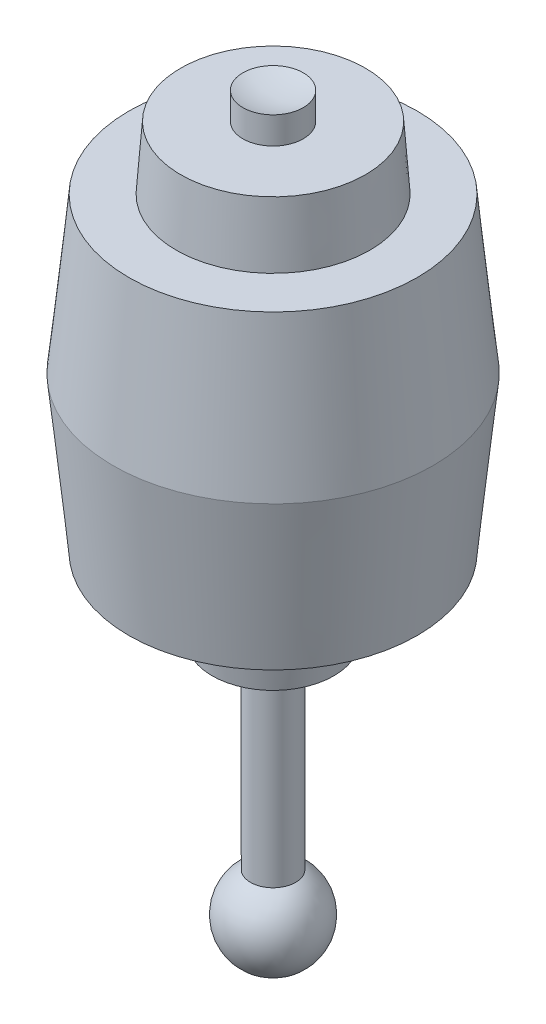
from build123d import *


with BuildPart() as part:
    # Sketch1 → Revolve1 (revolve)
    with BuildSketch(Plane.XY):
        with BuildLine():
            Line((-2.5, -47.669872981), (-2.5, -25.7))
            Line((-2.5, -25.7), (-6.75, -25.7))
            Line((-6.75, -25.7), (-7.75, -17.2))
            Line((-7.75, -17.2), (-16, -17.2))
            Line((-16, -17.2), (-17.75, 0))
            Line((-17.75, 0), (-16, 17.2))
            Line((-16, 17.2), (-10.75, 17.2))
            Line((-10.75, 17.2), (-10.25, 24.2))
            Line((-10.25, 24.2), (-3.35, 24.2))
            Line((-3.35, 24.2), (-3.35, 27.2))
            ThreePointArc((-3.35, 27.2), (-1.699733397, 26.767694664), (0, 26.622181276))
            Line((0, 26.622181276), (0, -57))
            ThreePointArc((0, -57), (-4.829629131, -53.294095226), (-2.5, -47.669872981))
        make_face()
    revolve(axis=Axis((0, -52, 0), (0, 1, 0)))


solid = part.part
